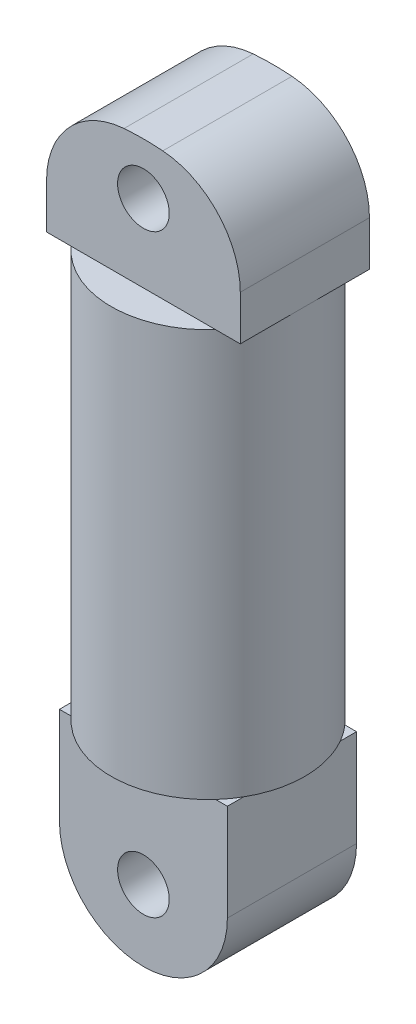
from build123d import *

# Parameters (mm, degrees)
SKETCH1_R           = 15
BOSS_EXTRUDE1_DEPTH = 63
SKETCH3_R           = 4
BOSS_EXTRUDE2_DEPTH = 10


with BuildPart() as part:
    # Sketch1 → Boss-Extrude1 (new body)
    with BuildSketch(Plane(origin=(0, 0, 0), x_dir=(1, 0, 0), z_dir=(0, 1, 0))):
        Circle(SKETCH1_R)
    extrude(amount=BOSS_EXTRUDE1_DEPTH)

    # Sketch3 → Boss-Extrude2 (add, symmetric)
    with BuildSketch(Plane.XY):
        with BuildLine():
            Line((-13, 0), (-13, -15))
            ThreePointArc((-13, -15), (0, -28), (13, -15))
            Line((13, -15), (13, 0))
            Line((13, 0), (-13, 0))
        make_face()
        with Locations((0, -17)):
            Circle(SKETCH3_R, mode=Mode.SUBTRACT)
        with BuildLine():
            Line((-15, 63), (15, 63))
            Line((15, 63), (15, 69.922962794))
            ThreePointArc((15, 69.922962794), (11.539392014, 78.75472366), (3, 82.88444419))
            ThreePointArc((3, 82.88444419), (0, 83), (-3, 82.88444419))
            ThreePointArc((-3, 82.88444419), (-11.539392014, 78.75472366), (-15, 69.922962794))
            Line((-15, 69.922962794), (-15, 63))
        make_face()
        with Locations((0, 75)):
            Circle(SKETCH3_R, mode=Mode.SUBTRACT)
    extrude(amount=BOSS_EXTRUDE2_DEPTH, both=True)


solid = part.part
